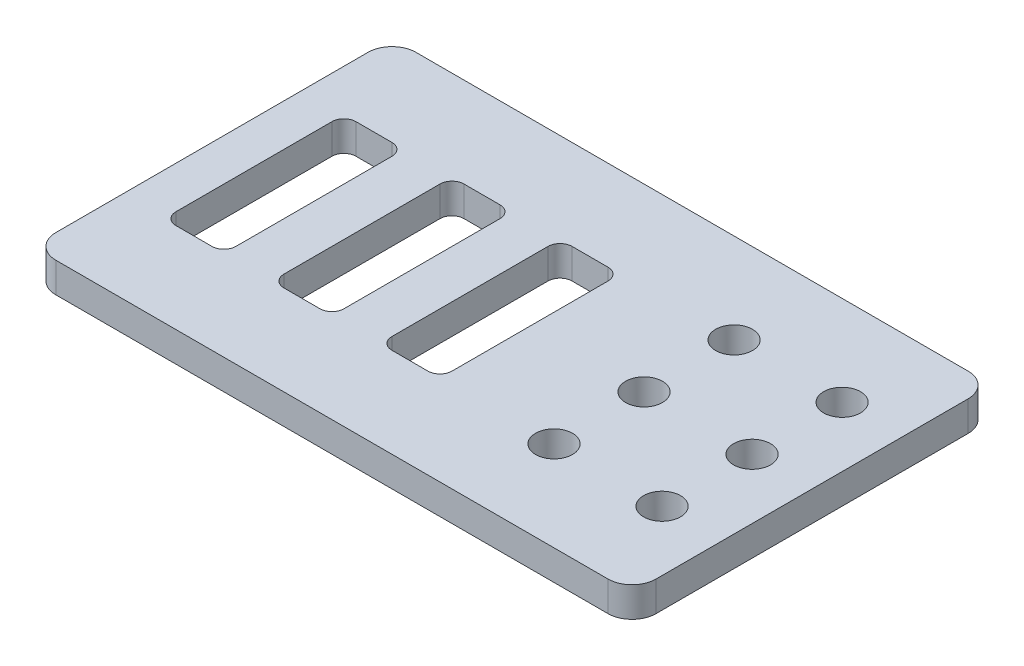
from build123d import *

# Parameters (mm, degrees)
SKETCH1_W              = 100
SKETCH1_H              = 60
BOSS_EXTRUDE1_DEPTH    = 5
CUT_EXTRUDE1_START     = -6
SKETCH2_R              = 3.075
CUT_EXTRUDE1_DEPTH     = 7
SKETCH3_W              = 10
SKETCH3_H              = 30
CUT_EXTRUDE2_DEPTH     = 6
FILLET2_R              = 2
LPATTERN1_COUNT        = 3
LPATTERN1_PITCH        = 18
FILLET2_OF_LPATTERN1_R = 2
LPATTERN2_COUNT        = 2
LPATTERN2_PITCH        = 18
FILLET1_R              = 4


with BuildPart() as part:
    # Sketch1 → Boss-Extrude1 (new body)
    with BuildSketch(Plane(origin=(0, 0, 0), x_dir=(1, 0, 0), z_dir=(0, 1, 0))):
        Rectangle(SKETCH1_W, SKETCH1_H)
    extrude(amount=BOSS_EXTRUDE1_DEPTH)

    # Sketch2 → Cut-Extrude1 (cut)
    with BuildSketch(Plane(origin=(0, 5, 0), x_dir=(1, 0, 0), z_dir=(0, 1, 0)).offset(CUT_EXTRUDE1_START)):
        with Locations((40, 15)):
            Circle(SKETCH2_R)
        with Locations((40, -15)):
            Circle(SKETCH2_R)
        with Locations((40, 0)):
            Circle(SKETCH2_R)
    cut_extrude1 = extrude(amount=CUT_EXTRUDE1_DEPTH, mode=Mode.SUBTRACT)

    # Sketch3 → Cut-Extrude2 (cut, through all)
    with BuildSketch(Plane(origin=(0, 5, 0), x_dir=(1, 0, 0), z_dir=(0, 1, 0))):
        with Locations((-38, 0)):
            Rectangle(SKETCH3_W, SKETCH3_H)
    cut_extrude2 = extrude(amount=-CUT_EXTRUDE2_DEPTH, mode=Mode.SUBTRACT)

    # Fillet2
    fillet2_edges = [part.edges().sort_by_distance(p)[0] for p in [
        (-33, 2.5, -15),
        (-33, 2.5, 15),
        (-43, 2.5, 15),
        (-43, 2.5, -15),
    ]]
    fillet(fillet2_edges, radius=FILLET2_R)

    # LPattern1: Cut-Extrude2 ×3
    with Locations(*[(i * LPATTERN1_PITCH, 0, 0) for i in range(1, LPATTERN1_COUNT)]):
        add(cut_extrude2, mode=Mode.SUBTRACT)

    # Fillet2 of LPattern1
    fillet2_of_lpattern1_edges = [part.edges().sort_by_distance(p)[0] for p in [
        (-15, 2.5, -15),
        (-15, 2.5, 15),
        (-25, 2.5, 15),
        (-25, 2.5, -15),
        (3, 2.5, -15),
        (3, 2.5, 15),
        (-7, 2.5, 15),
        (-7, 2.5, -15),
    ]]
    fillet(fillet2_of_lpattern1_edges, radius=FILLET2_OF_LPATTERN1_R)

    # LPattern2: Cut-Extrude1 ×2
    with Locations(*[(-i * LPATTERN2_PITCH, 0, 0) for i in range(1, LPATTERN2_COUNT)]):
        add(cut_extrude1, mode=Mode.SUBTRACT)

    # Fillet1
    fillet1_edges = [part.edges().sort_by_distance(p)[0] for p in [
        (50, 2.5, 30),
        (-50, 2.5, 30),
        (-50, 2.5, -30),
        (50, 2.5, -30),
    ]]
    fillet(fillet1_edges, radius=FILLET1_R)


solid = part.part
